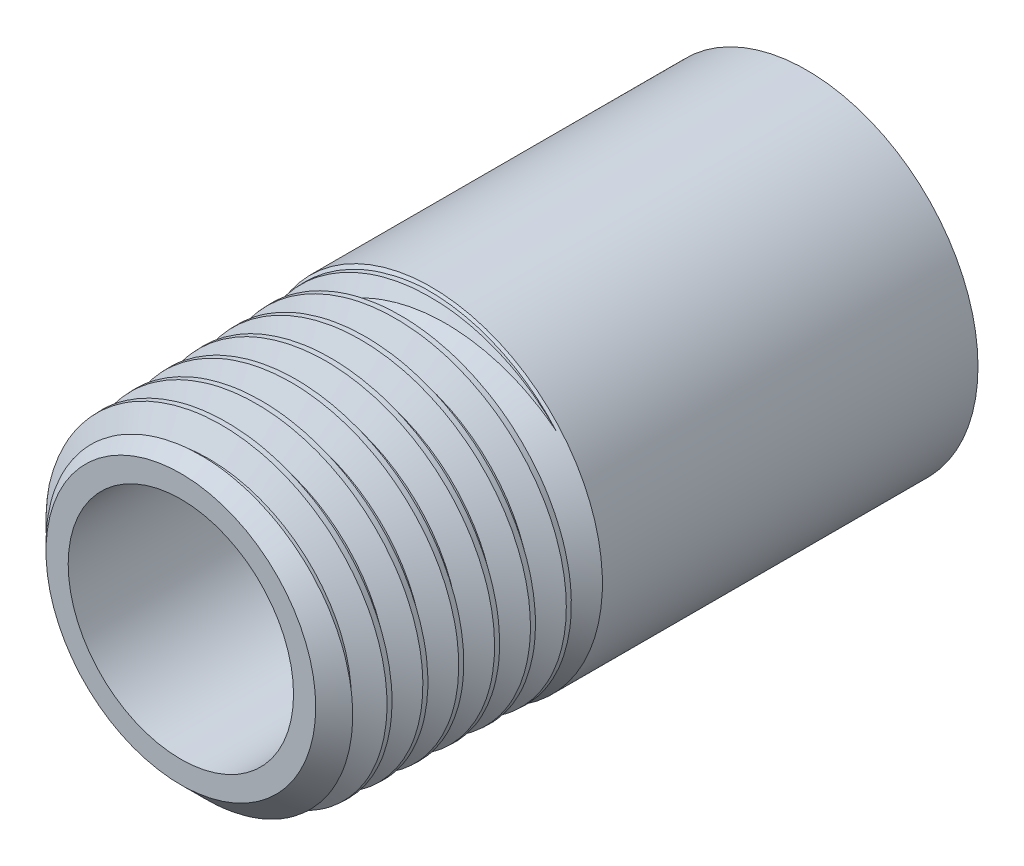
from build123d import *

# Parameters (mm, degrees)
SKETCH4_OUTSIDE_W               = 50.188
SKETCH4_OUTSIDE_H               = 50.188
SKETCH4_OUTSIDE_R               = 5.472366642
CUT_EXTRUDE2_DEPTH              = 15.045993308
CUT_EXTRUDE2_DRAFT              = -45
CUT_SWEEP1_PITCH                = 1.411794907
CUT_SWEEP1_HEIGHT               = 11.571111111
CUT_SWEEP1_RADIUS               = 6.541667453
CUT_SWEEP1_START_ANGLE          = 90
BOSS_EXTRUDE2_REACH             = 18.055
SKETCH13_R                      = 6.9453125
BOSS_EXTRUDE2_DIRECTION_2_DEPTH = 12.7
CUT_EXTRUDE3_DEPTH              = 17.055053309
CUT_EXTRUDE3_DEPTH_BACK         = 17.055053309
SKETCH15_R                      = 4.572


with BuildPart() as part:
    # Sketch2 → Revolve1 (revolve)
    with BuildSketch(Plane(origin=(0, 0, 0), x_dir=(0, 0, -1), z_dir=(1, 0, 0)), mode=Mode.PRIVATE) as revolve1_sk:
        Polygon((-12.7, 6.541667453), (-2.54, 6.858), (-2.54, 0), (-12.7, 0), align=None)
    revolve(revolve1_sk.sketch.rotate(Axis((0, 0, 12.7), (0, 0, -1)), 90), axis=Axis((0, 0, 12.7), (0, 0, -1)))


with BuildPart() as cut_extrude2_tool:
    # Sketch4 outside → Cut-Extrude2 (with draft: the straight prism first)
    with BuildSketch(Plane.XY.offset(12.7)):
        Rectangle(SKETCH4_OUTSIDE_W, SKETCH4_OUTSIDE_H)
        Circle(SKETCH4_OUTSIDE_R, mode=Mode.SUBTRACT)
    extrude(amount=-CUT_EXTRUDE2_DEPTH)
    # Cut-Extrude2: the draft: its side faces are tilted about the plane it starts from
    cut_extrude2_sides = [cut_extrude2_tool.faces().sort_by_distance(p)[0] for p in [
        (0, -25.094, 5.177003346),
        (25.094, 0, 5.177003346),
        (0, 25.094, 5.177003346),
        (-25.094, 0, 5.177003346),
        (-5.472366642, 0, 5.177003346),
    ]]
    draft(cut_extrude2_sides, Plane.XY.offset(12.7), CUT_EXTRUDE2_DRAFT)


with BuildPart() as part_1:
    add(part.part)

    # Cut-Extrude2: cut by cut_extrude2_tool
    add(cut_extrude2_tool.part, mode=Mode.SUBTRACT)

    # Cut-Sweep1: sweep along a helix
    with BuildLine() as cut_sweep1_path:
        # a taper helix: rise per turn along the axis 1.411111111, along the cone's slant (build123d's pitch) 1.411794907
        add(Helix(CUT_SWEEP1_PITCH, CUT_SWEEP1_HEIGHT, CUT_SWEEP1_RADIUS, center=(0, 0, 12.7), direction=(0, 0, -1), cone_angle=1.783333333, mode=Mode.PRIVATE).rotate(Axis((0, 0, 12.7), (0, 0, -1)), CUT_SWEEP1_START_ANGLE))
    # Profile → Cut-Sweep1 (sweep, cut)
    with BuildSketch(Plane(origin=(0, 0, 0), x_dir=(0, 0, -1), z_dir=(1, 0, 0))):
        Polygon((-14.022916667, 6.694424712), (-12.655902778, 6.618046082), (-13.229166667, 5.625123901), (-13.405555556, 5.625123901), align=None)
    sweep(path=cut_sweep1_path.line, is_frenet=True, mode=Mode.SUBTRACT)

    # Boss-Extrude1 cone 1 section (through the dimple's axis) → Boss-Extrude1 (revolve)
    with BuildSketch(Plane(origin=(0, 0, 2.54), x_dir=(0, 1, 0), z_dir=(1, 0, 0))):
        Polygon((0, 0), (6.9453125, 0), (0, 6.9453125), align=None)
    revolve(axis=Axis((0, 0, 2.54), (0, 0, 1)))

    # Boss-Extrude2: up to this cone (the profile starts inside it)
    boss_extrude2_end = Plane(origin=(0, 0, 0), z_dir=(0, 0, -1)).offset(-9.4853115) * Cone(1e-06, 37.525625, 37.525624, align=(Align.CENTER, Align.CENTER, Align.MIN), mode=Mode.PRIVATE)
    # Sketch13 → Boss-Extrude2 (add, up to the surface)
    with BuildSketch(Plane.XY, mode=Mode.PRIVATE) as boss_extrude2_sk1:
        with Locations(Location((0, 0, 0), (0, 0, 180))):
            Circle(SKETCH13_R)
    boss_extrude2_tool1 = extrude(boss_extrude2_sk1.sketch, amount=BOSS_EXTRUDE2_REACH, mode=Mode.PRIVATE) & boss_extrude2_end
    add(boss_extrude2_tool1.solids().sort_by_distance((0, 0, 0))[0])

    # Sketch13 → Boss-Extrude2 direction 2 (add)
    with BuildSketch(Plane.XY):
        with Locations(Location((0, 0, 0), (0, 0, 180))):
            Circle(SKETCH13_R)
    extrude(amount=-BOSS_EXTRUDE2_DIRECTION_2_DEPTH)

    # Sketch15 → Cut-Extrude3 (cut, two sides: drawn at the far end of the back side and taken through both)
    with BuildSketch(Plane.XY.offset(-CUT_EXTRUDE3_DEPTH_BACK)):
        Circle(SKETCH15_R)
    extrude(amount=CUT_EXTRUDE3_DEPTH + CUT_EXTRUDE3_DEPTH_BACK, mode=Mode.SUBTRACT)


solid = part_1.part
